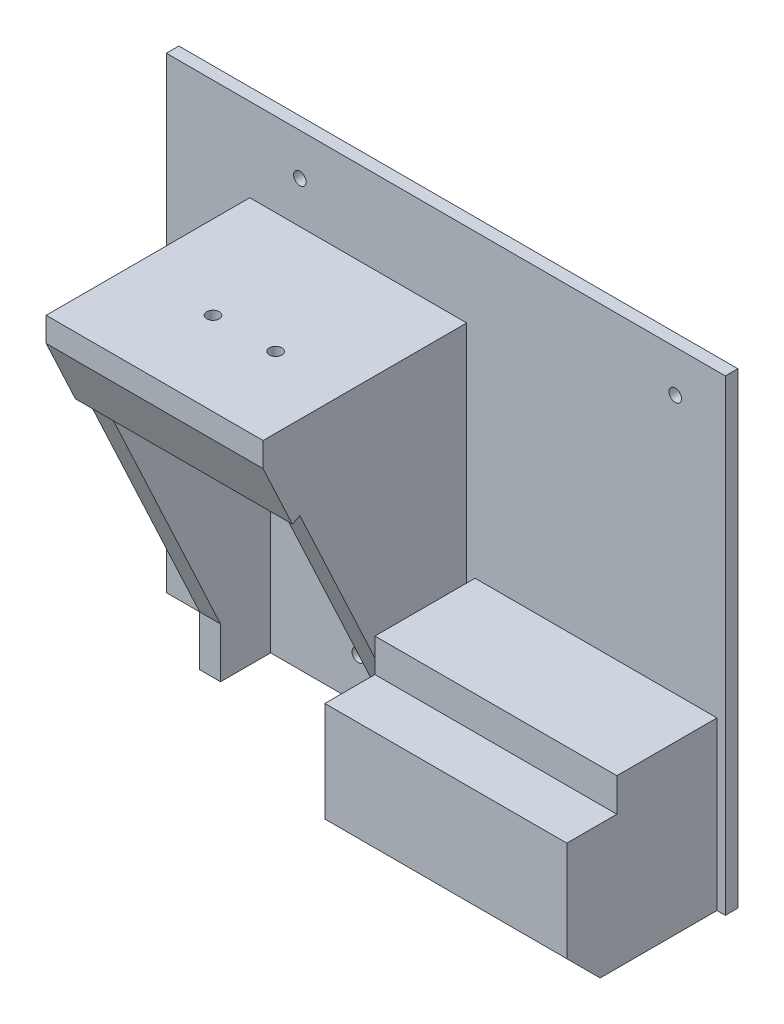
from build123d import *

# Parameters (mm, degrees)
SKETCH1_W           = 72
SKETCH1_H           = 92
BOSS_EXTRUDE1_DEPTH = 3
SKETCH2_W           = 5
SKETCH2_H           = 92
BOSS_EXTRUDE2_DEPTH = 47
BOSS_EXTRUDE3_REACH = 52
SKETCH3_W           = 52
SKETCH3_H           = 20
CUT_EXTRUDE3_REACH  = 54
SKETCH8_W           = 52
SKETCH8_H           = 16.552945357
BOSS_EXTRUDE5_DEPTH = 2
SKETCH9_W           = 52
SKETCH9_H           = 5
SKETCH9_H_2         = 0.845770931
BOSS_EXTRUDE6_DEPTH = 1.812366
SKETCH10_W          = 42
SKETCH10_H          = 40
CUT_EXTRUDE4_DEPTH  = 17
CUT_EXTRUDE5_REACH  = 94
SKETCH12_R          = 1.5
SKETCH13_W          = 72
SKETCH13_H          = 3
BOSS_EXTRUDE7_DEPTH = 20
SKETCH15_W          = 3
SKETCH15_H          = 112
BOSS_EXTRUDE8_DEPTH = 62
SKETCH17_W          = 58
SKETCH17_H          = 40
BOSS_EXTRUDE9_DEPTH = 36
CHAMFER1_SIZE       = 8
SKETCH18_W          = 58
SKETCH18_H          = 8
CUT_EXTRUDE8_DEPTH  = 12
CUT_EXTRUDE9_REACH  = 5
SKETCH14_R          = 1.5


with BuildPart() as part:
    # Sketch1 → Boss-Extrude1 (new body)
    with BuildSketch(Plane.XY):
        Rectangle(SKETCH1_W, SKETCH1_H)
    extrude(amount=BOSS_EXTRUDE1_DEPTH)

    # Sketch2 → Boss-Extrude2 (add)
    with BuildSketch(Plane.XY.offset(3)):
        with Locations((33.5, 0)):
            Rectangle(SKETCH2_W, SKETCH2_H)
        with Locations((-13.5, 0)):
            Rectangle(SKETCH2_W, SKETCH2_H)
    extrude(amount=BOSS_EXTRUDE2_DEPTH)

    # Sketch3 → Boss-Extrude3 (add, up to next)
    with BuildSketch(Plane.XY.offset(50), mode=Mode.PRIVATE) as boss_extrude3_sk1:
        with Locations((10, 36)):
            Rectangle(SKETCH3_W, SKETCH3_H)
    boss_extrude3_tool1 = extrude(boss_extrude3_sk1.sketch, amount=-BOSS_EXTRUDE3_REACH, mode=Mode.PRIVATE) - part.part
    add(boss_extrude3_tool1.solids().sort_by_distance((10, 36, 50))[0])

    # Sketch7 → Cut-Extrude3 (cut, up to next)
    with BuildSketch(Plane.ZY.offset(16), mode=Mode.PRIVATE) as cut_extrude3_sk1:
        Polygon((50, 41), (15, -34), (15, -46), (50, -46), align=None)
    cut_extrude3_tool1 = extrude(cut_extrude3_sk1.sketch, amount=-CUT_EXTRUDE3_REACH, mode=Mode.PRIVATE) & part.part
    add(cut_extrude3_tool1.solids().sort_by_distance((-16, -16.515152, 36.919192))[0], mode=Mode.SUBTRACT)

    # Sketch8 → Boss-Extrude5 (add)
    with BuildSketch(Plane(origin=(0, -11.828467153, 25.346715328), x_dir=(1, 0, 0), z_dir=(0, -0.422885465, 0.90618314))):
        with Locations((10, 50.021309328)):
            Rectangle(SKETCH8_W, SKETCH8_H)
    extrude(amount=BOSS_EXTRUDE5_DEPTH)

    # Sketch9 → Boss-Extrude6 (add)
    with BuildSketch(Plane.XY.offset(50)):
        with Locations((10, 43.5)):
            Rectangle(SKETCH9_W, SKETCH9_H)
        with Locations((10, 40.577114534)):
            Rectangle(SKETCH9_W, SKETCH9_H_2)
    extrude(amount=BOSS_EXTRUDE6_DEPTH)

    # Sketch10 → Cut-Extrude4 (cut)
    with BuildSketch(Plane.XZ.offset(-26)):
        with Locations((10, 23)):
            Rectangle(SKETCH10_W, SKETCH10_H)
    extrude(amount=-CUT_EXTRUDE4_DEPTH, mode=Mode.SUBTRACT)

    # Sketch12 → Cut-Extrude5 (cut, up to next)
    with BuildSketch(Plane(origin=(0, 46, 0), x_dir=(1, 0, 0), z_dir=(0, 1, 0)), mode=Mode.PRIVATE) as cut_extrude5_sk1:
        with Locations((4, -31.81236628)):
            Circle(SKETCH12_R)
    cut_extrude5_tool1 = extrude(cut_extrude5_sk1.sketch, amount=-CUT_EXTRUDE5_REACH, mode=Mode.PRIVATE) & part.part
    add(cut_extrude5_tool1.solids().sort_by_distance((4, 46, 31.812366))[0], mode=Mode.SUBTRACT)
    # Sketch12 → Cut-Extrude5 (cut, up to next)
    with BuildSketch(Plane(origin=(0, 46, 0), x_dir=(1, 0, 0), z_dir=(0, 1, 0)), mode=Mode.PRIVATE) as cut_extrude5_sk2:
        with Locations((19, -31.81236628)):
            Circle(SKETCH12_R)
    cut_extrude5_tool2 = extrude(cut_extrude5_sk2.sketch, amount=-CUT_EXTRUDE5_REACH, mode=Mode.PRIVATE) & part.part
    add(cut_extrude5_tool2.solids().sort_by_distance((19, 46, 31.812366))[0], mode=Mode.SUBTRACT)

    # Sketch13 → Boss-Extrude7 (add)
    with BuildSketch(Plane(origin=(0, 46, 0), x_dir=(1, 0, 0), z_dir=(0, 1, 0))):
        with Locations((0, -1.5)):
            Rectangle(SKETCH13_W, SKETCH13_H)
    extrude(amount=BOSS_EXTRUDE7_DEPTH)

    # Sketch15 → Boss-Extrude8 (add)
    with BuildSketch(Plane(origin=(36, 0, 0), x_dir=(0, 0, -1), z_dir=(1, 0, 0))):
        with Locations((-1.5, 10)):
            Rectangle(SKETCH15_W, SKETCH15_H)
    extrude(amount=BOSS_EXTRUDE8_DEPTH)

    # Sketch17 → Boss-Extrude9 (add)
    with BuildSketch(Plane.XY.offset(3)):
        with Locations((67, -26)):
            Rectangle(SKETCH17_W, SKETCH17_H)
    extrude(amount=BOSS_EXTRUDE9_DEPTH)

    # Chamfer1
    chamfer1_edges = [part.edges().sort_by_distance(p)[0] for p in [
        (67, -46, 39),
    ]]
    chamfer(chamfer1_edges, length=CHAMFER1_SIZE)

    # Sketch18 → Cut-Extrude8 (cut)
    with BuildSketch(Plane.XY.offset(39)):
        with Locations((67, -10)):
            Rectangle(SKETCH18_W, SKETCH18_H)
    extrude(amount=-CUT_EXTRUDE8_DEPTH, mode=Mode.SUBTRACT)

    # Sketch14 → Cut-Extrude9 (cut, up to next)
    with BuildSketch(Plane.XY.offset(3), mode=Mode.PRIVATE) as cut_extrude9_sk1:
        with Locations((86, 56)):
            Circle(SKETCH14_R)
    cut_extrude9_tool1 = extrude(cut_extrude9_sk1.sketch, amount=-CUT_EXTRUDE9_REACH, mode=Mode.PRIVATE) & part.part
    add(cut_extrude9_tool1.solids().sort_by_distance((86, 56, 3))[0], mode=Mode.SUBTRACT)
    # Sketch14 → Cut-Extrude9 (cut, up to next)
    with BuildSketch(Plane.XY.offset(3), mode=Mode.PRIVATE) as cut_extrude9_sk2:
        with Locations((10, -36)):
            Circle(SKETCH14_R)
    cut_extrude9_tool2 = extrude(cut_extrude9_sk2.sketch, amount=-CUT_EXTRUDE9_REACH, mode=Mode.PRIVATE) & part.part
    add(cut_extrude9_tool2.solids().sort_by_distance((10, -36, 3))[0], mode=Mode.SUBTRACT)
    # Sketch14 → Cut-Extrude9 (cut, up to next)
    with BuildSketch(Plane.XY.offset(3), mode=Mode.PRIVATE) as cut_extrude9_sk3:
        with Locations((-4, 56)):
            Circle(SKETCH14_R)
    cut_extrude9_tool3 = extrude(cut_extrude9_sk3.sketch, amount=-CUT_EXTRUDE9_REACH, mode=Mode.PRIVATE) & part.part
    add(cut_extrude9_tool3.solids().sort_by_distance((-4, 56, 3))[0], mode=Mode.SUBTRACT)


solid = part.part
